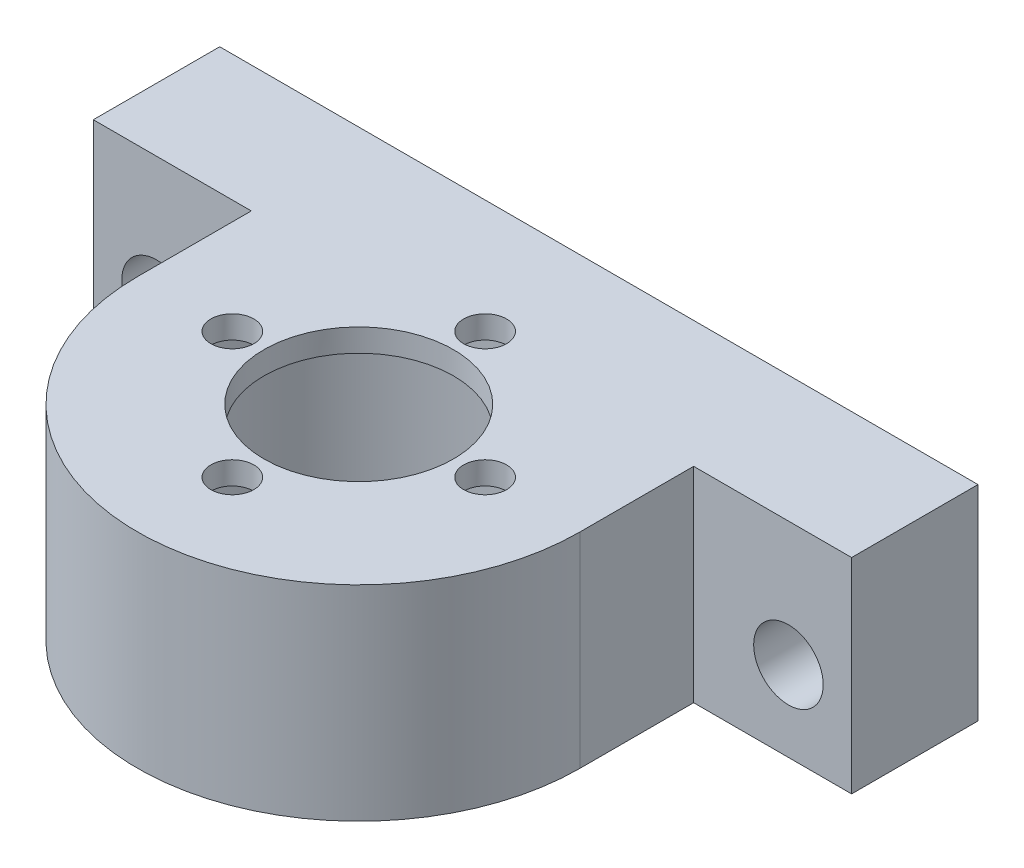
from build123d import *

# Parameters (mm, degrees)
SKETCH2_R                = 13
BOSS_EXTRUDE1_DEPTH      = 12.7
M5_CLEARANCE_HOLE1_D     = 5.5
M5_CLEARANCE_HOLE1_DEPTH = 10.1
M5_CLEARANCE_HOLE1_TIP   = 1.652366702
BOSS_EXTRUDE2_DEPTH      = 3.5
SKETCH10_R               = 13
CUT_EXTRUDE1_DEPTH       = 1.7
SKETCH11_R               = 7.5
CUT_EXTRUDE2_DEPTH       = 17.2
M3_CLEARANCE_HOLE1_D     = 3.4
M3_CLEARANCE_HOLE1_DEPTH = 7.5
M3_CLEARANCE_HOLE1_TIP   = 1.021463052


with BuildPart() as part:
    # Sketch2 → Boss-Extrude1 (new body)
    with BuildSketch(Plane(origin=(0, 0, 0), x_dir=(1, 0, 0), z_dir=(0, 1, 0))):
        with BuildLine():
            Line((-30, 9), (-17.5, 9))
            Line((-17.5, 9), (-17.5, 0))
            ThreePointArc((-17.5, 0), (0, -17.5), (17.5, 0))
            Line((17.5, 0), (17.5, 9))
            Line((17.5, 9), (30, 9))
            Line((30, 9), (30, 19))
            Line((30, 19), (-30, 19))
            Line((-30, 19), (-30, 9))
        make_face()
        Circle(SKETCH2_R, mode=Mode.SUBTRACT)
    extrude(amount=BOSS_EXTRUDE1_DEPTH)

    # M5 Clearance Hole1
    with Locations(Plane(origin=(-25, 6.35, -19), x_dir=(-1, 0, 0), z_dir=(0, 0, -1))):
        with Locations((0, 0), (-50, 0)):
            Hole(M5_CLEARANCE_HOLE1_D / 2, depth=M5_CLEARANCE_HOLE1_DEPTH)
            with Locations((0, 0, -(M5_CLEARANCE_HOLE1_DEPTH + M5_CLEARANCE_HOLE1_TIP / 2))):  # 118° drill point
                Cone(0, M5_CLEARANCE_HOLE1_D / 2, M5_CLEARANCE_HOLE1_TIP, mode=Mode.SUBTRACT)

    # Sketch9 → Boss-Extrude2 (add)
    with BuildSketch(Plane(origin=(0, 12.7, 0), x_dir=(1, 0, 0), z_dir=(0, 1, 0))):
        with BuildLine():
            Line((-30, 9), (-17.5, 9))
            Line((-17.5, 9), (-17.5, 0))
            ThreePointArc((-17.5, 0), (0, -17.5), (17.5, 0))
            Line((17.5, 0), (17.5, 9))
            Line((17.5, 9), (30, 9))
            Line((30, 9), (30, 19))
            Line((30, 19), (-30, 19))
            Line((-30, 19), (-30, 9))
        make_face()
    extrude(amount=BOSS_EXTRUDE2_DEPTH)

    # Sketch10 → Cut-Extrude1 (cut)
    with BuildSketch(Plane.XZ.offset(-12.7)):
        Circle(SKETCH10_R)
    extrude(amount=-CUT_EXTRUDE1_DEPTH, mode=Mode.SUBTRACT)

    # Sketch11 → Cut-Extrude2 (cut, through all)
    with BuildSketch(Plane(origin=(0, 16.2, 0), x_dir=(1, 0, 0), z_dir=(0, 1, 0))):
        Circle(SKETCH11_R)
    extrude(amount=-CUT_EXTRUDE2_DEPTH, mode=Mode.SUBTRACT)

    # M3 Clearance Hole1
    with Locations(Plane(origin=(-10, 16.2, 0), x_dir=(0, 0, 1), z_dir=(0, 1, 0))):
        with Locations((0, 0), (10, 10), (0, 20), (-10, 10)):
            Hole(M3_CLEARANCE_HOLE1_D / 2, depth=M3_CLEARANCE_HOLE1_DEPTH)
            with Locations((0, 0, -(M3_CLEARANCE_HOLE1_DEPTH + M3_CLEARANCE_HOLE1_TIP / 2))):  # 118° drill point
                Cone(0, M3_CLEARANCE_HOLE1_D / 2, M3_CLEARANCE_HOLE1_TIP, mode=Mode.SUBTRACT)


solid = part.part
